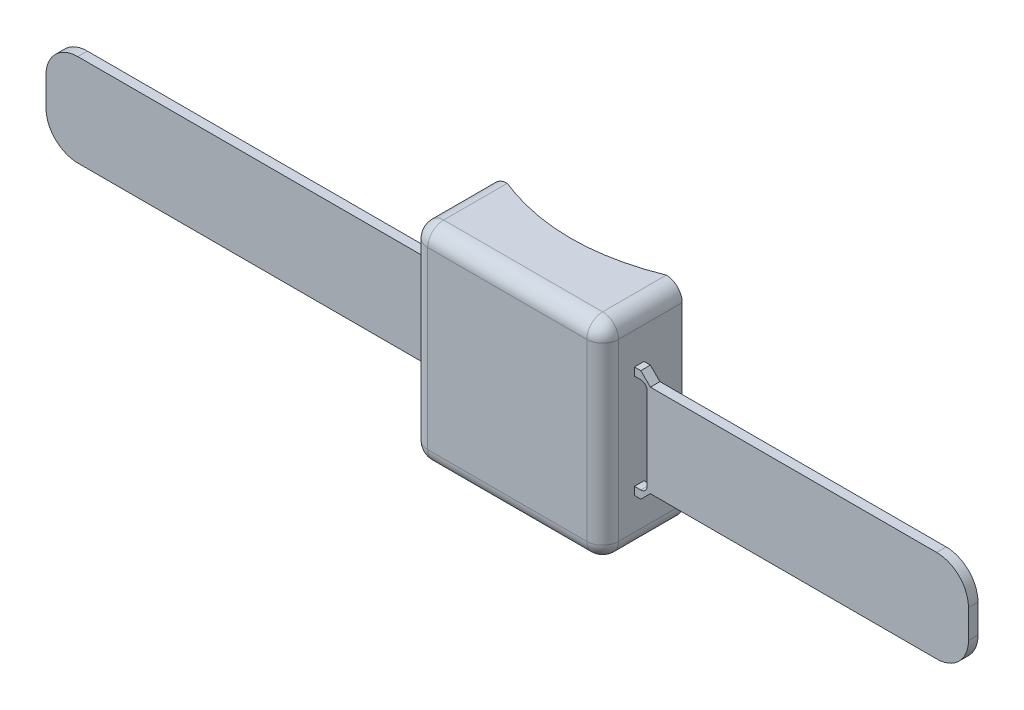
from build123d import *

# Parameters (mm, degrees)
SALIENTE_EXTRUIR1_DEPTH = 25
REDONDEO1_R             = 5
CORTAR_EXTRUIR1_DEPTH   = 65
CROQUIS3_W              = 3
CROQUIS3_H              = 35
SALIENTE_EXTRUIR2_DEPTH = 5
CORTAR_EXTRUIR2_DEPTH   = 3
CHAFL_N2_SIZE           = 3
CHAFL_N3_SIZE           = 3
CROQUIS6_R              = 9
CORTAR_EXTRUIR5_DEPTH   = 1.5
CORTAR_EXTRUIR6_DEPTH   = 2.5
CROQUIS9_W              = 3
CROQUIS9_H              = 29
SALIENTE_EXTRUIR3_DEPTH = 120
CORTAR_EXTRUIR7_DEPTH   = 3
CROQUIS11_W             = 3
CROQUIS11_H             = 29
SALIENTE_EXTRUIR4_DEPTH = 100
CORTAR_EXTRUIR8_DEPTH   = 3


with BuildPart() as part:
    # Croquis1 → Saliente-Extruir1 (new body)
    with BuildSketch(Plane.XY):
        with BuildLine():
            Line((5, 0), (55, 0))
            ThreePointArc((55, 0), (58.535533906, 1.464466094), (60, 5))
            Line((60, 5), (60, 60))
            ThreePointArc((60, 60), (58.535533906, 63.535533906), (55, 65))
            Line((55, 65), (5, 65))
            ThreePointArc((5, 65), (1.464466094, 63.535533906), (0, 60))
            Line((0, 60), (0, 5))
            ThreePointArc((0, 5), (1.464466094, 1.464466094), (5, 0))
        make_face()
    extrude(amount=-SALIENTE_EXTRUIR1_DEPTH)

    # Redondeo1
    redondeo1_edges = [part.edges().sort_by_distance(p)[0] for p in [
        (30, 0, 0),
        (1.464466094, 1.464466094, 0),
        (0, 32.5, 0),
        (1.464466094, 63.535533906, 0),
        (30, 65, 0),
        (58.535533906, 63.535533906, 0),
        (60, 32.5, 0),
        (58.535533906, 1.464466094, 0),
    ]]
    fillet(redondeo1_edges, radius=REDONDEO1_R)

    # Croquis2 → Cortar-Extruir1 (cut)
    with BuildSketch(Plane.XZ):
        with BuildLine():
            Line((5, -25), (55, -25))
            add(Edge.make_bspline(
                [(5, -25), (30, -15), (55, -25)],
                knots=[0, 0, 0, 1, 1, 1], degree=2))
        make_face()
    extrude(amount=-CORTAR_EXTRUIR1_DEPTH, mode=Mode.SUBTRACT)

    # Croquis3 → Saliente-Extruir2 (add)
    with BuildSketch(Plane.ZY):
        with Locations((-11.5, 32.5)):
            Rectangle(CROQUIS3_W, CROQUIS3_H)
    saliente_extruir2 = extrude(amount=SALIENTE_EXTRUIR2_DEPTH)

    # Croquis4 → Cortar-Extruir2 (cut)
    with BuildSketch(Plane.XY.offset(-10)):
        with BuildLine():
            Line((-2, 47.5), (0, 47.5))
            Line((0, 47.5), (0, 17.5))
            Line((0, 17.5), (-2, 17.5))
            ThreePointArc((-2, 17.5), (-3.414213562, 18.085786438), (-4, 19.5))
            Line((-4, 19.5), (-4, 45.5))
            ThreePointArc((-4, 45.5), (-3.414213562, 46.914213562), (-2, 47.5))
        make_face()
    cortar_extruir2 = extrude(amount=-CORTAR_EXTRUIR2_DEPTH, mode=Mode.SUBTRACT)

    # Chaflán2
    chafl_n2_edges = [part.edges().sort_by_distance(p)[0] for p in [
        (-5, 15, -11.5),
        (-5, 50, -11.5),
    ]]
    chamfer(chafl_n2_edges, length=CHAFL_N2_SIZE)

    # Simetría1: Saliente-Extruir2 across plane
    add(saliente_extruir2.mirror(Plane(origin=(30, 0, 0), x_dir=(0, 0, 1), z_dir=(1, 0, 0))))

    # Simetría2: Cortar-Extruir2 across plane
    add(cortar_extruir2.mirror(Plane(origin=(30, 0, 0), x_dir=(0, 0, 1), z_dir=(1, 0, 0))), mode=Mode.SUBTRACT)

    # Chaflán3
    chafl_n3_edges = [part.edges().sort_by_distance(p)[0] for p in [
        (65, 15, -11.5),
        (65, 50, -11.5),
    ]]
    chamfer(chafl_n3_edges, length=CHAFL_N3_SIZE)

    # Croquis6 → Cortar-Extruir5 (cut)
    with BuildSketch(Plane.XY.offset(-19.5)):
        with Locations((30, 32.5)):
            Circle(CROQUIS6_R)
    extrude(amount=-CORTAR_EXTRUIR5_DEPTH, mode=Mode.SUBTRACT)

    # Croquis7 → Cortar-Extruir6 (cut)
    with BuildSketch(Plane.XZ):
        with BuildLine():
            Line((26, -9), (34, -9))
            ThreePointArc((34, -9), (34.707106781, -9.292893219), (35, -10))
            Line((35, -10), (35, -12))
            ThreePointArc((35, -12), (34.707106781, -12.707106781), (34, -13))
            Line((34, -13), (26, -13))
            ThreePointArc((26, -13), (25.292893219, -12.707106781), (25, -12))
            Line((25, -12), (25, -10))
            ThreePointArc((25, -10), (25.292893219, -9.292893219), (26, -9))
        make_face()
    extrude(amount=-CORTAR_EXTRUIR6_DEPTH, mode=Mode.SUBTRACT)

    # Croquis11 → Saliente-Extruir4 (add)
    with BuildSketch(Plane(origin=(65, 0, 0), x_dir=(0, 0, -1), z_dir=(1, 0, 0))):
        with Locations((11.5, 32.5)):
            Rectangle(CROQUIS11_W, CROQUIS11_H)
    extrude(amount=SALIENTE_EXTRUIR4_DEPTH)

    # Croquis12 → Cortar-Extruir8 (cut)
    with BuildSketch(Plane.XY.offset(-10)):
        with BuildLine():
            ThreePointArc((165, 28), (162.071067812, 20.928932188), (155, 18))
            Line((155, 18), (165, 18))
            Line((165, 18), (165, 28))
        make_face()
        with BuildLine():
            Line((165, 47), (155, 47))
            ThreePointArc((155, 47), (162.071067812, 44.071067812), (165, 37))
            Line((165, 37), (165, 47))
        make_face()
    extrude(amount=-CORTAR_EXTRUIR8_DEPTH, mode=Mode.SUBTRACT)


with BuildPart() as body_2:
    # Croquis9 → Saliente-Extruir3 (new body)
    with BuildSketch(Plane.ZY.offset(5)):
        with Locations((-11.5, 32.5)):
            Rectangle(CROQUIS9_W, CROQUIS9_H)
    extrude(amount=SALIENTE_EXTRUIR3_DEPTH)

    # Croquis10 → Cortar-Extruir7 (cut)
    with BuildSketch(Plane.XY.offset(-10)):
        with BuildLine():
            ThreePointArc((-125, 37), (-122.071067812, 44.071067812), (-115, 47))
            Line((-115, 47), (-125, 47))
            Line((-125, 47), (-125, 37))
        make_face()
        with BuildLine():
            Line((-125, 18), (-115, 18))
            ThreePointArc((-115, 18), (-122.071067812, 20.928932188), (-125, 28))
            Line((-125, 28), (-125, 18))
        make_face()
    extrude(amount=-CORTAR_EXTRUIR7_DEPTH, mode=Mode.SUBTRACT)


solid = Compound([part.part, body_2.part])
